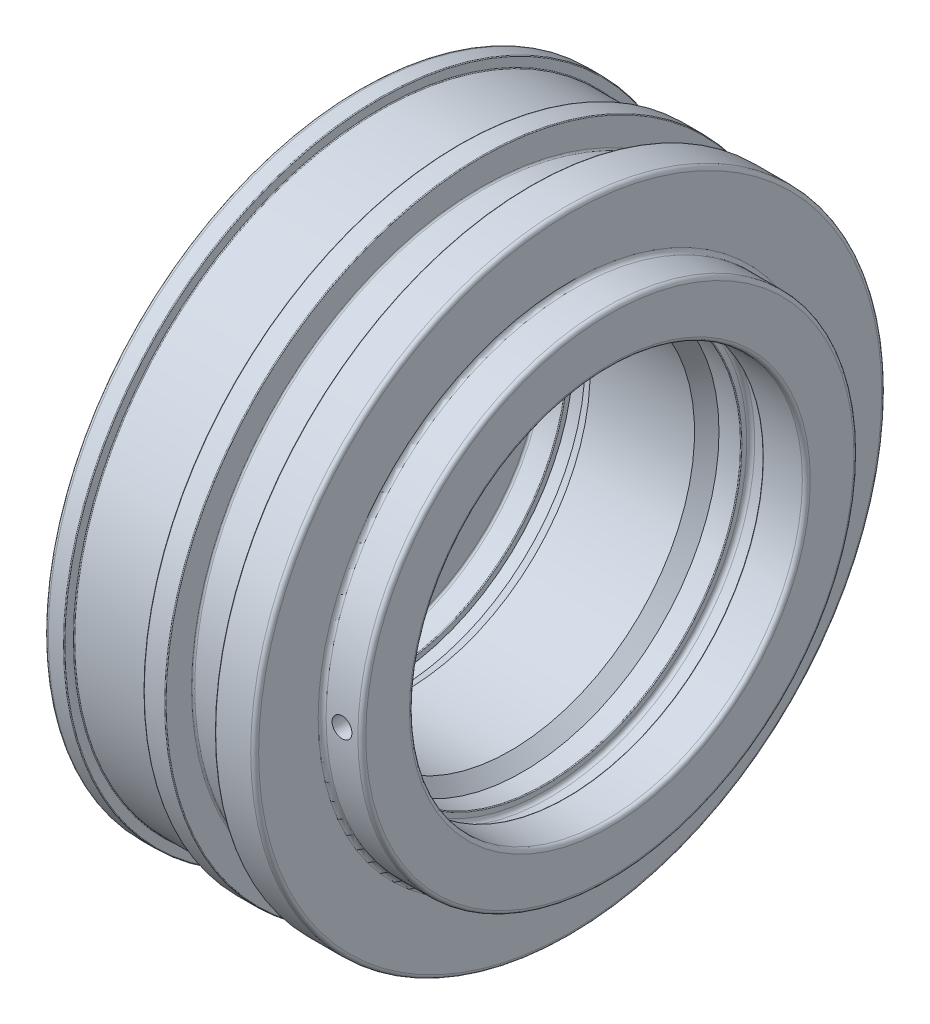
from build123d import *

# Parameters (mm, degrees)
SKETCH2_R          = 2.5
M6_GEVINDHUL_DEPTH = 80.5


with BuildPart() as part:
    # Sketch1 → Base-Revolve (revolve)
    with BuildSketch(Plane.XY):
        with BuildLine():
            Line((15, 67.914213562), (15, 78.5))
            ThreePointArc((15, 78.5), (15.292893219, 79.207106781), (16, 79.5))
            Line((16, 79.5), (19.8, 79.5))
            ThreePointArc((19.8, 79.5), (19.941421356, 79.441421356), (20, 79.3))
            Line((20, 79.3), (20, 77.2))
            ThreePointArc((20, 77.2), (20.058578644, 77.058578644), (20.2, 77))
            Line((20.2, 77), (39.8, 77))
            ThreePointArc((39.8, 77), (39.941421356, 77.058578644), (40, 77.2))
            Line((40, 77.2), (40, 79.3))
            ThreePointArc((40, 79.3), (40.058578644, 79.441421356), (40.2, 79.5))
            Line((40.2, 79.5), (45.3, 79.5))
            ThreePointArc((45.3, 79.5), (45.441421356, 79.441421356), (45.5, 79.3))
            Line((45.5, 79.3), (45.5, 72.9))
            ThreePointArc((45.5, 72.9), (45.617157288, 72.617157288), (45.9, 72.5))
            Line((45.9, 72.5), (57.6, 72.5))
            ThreePointArc((57.6, 72.5), (57.882842712, 72.617157288), (58, 72.9))
            Line((58, 72.9), (58, 79.3))
            ThreePointArc((58, 79.3), (58.058578644, 79.441421356), (58.2, 79.5))
            Line((58.2, 79.5), (67, 79.5))
            ThreePointArc((67, 79.5), (67.707106781, 79.207106781), (68, 78.5))
            Line((68, 78.5), (68, 63.5))
            ThreePointArc((68, 63.5), (68.292893219, 62.792893219), (69, 62.5))
            Line((69, 62.5), (77, 62.5))
            ThreePointArc((77, 62.5), (77.707106781, 62.207106781), (78, 61.5))
            Line((78, 61.5), (78, 50.5))
            ThreePointArc((78, 50.5), (77.707106781, 49.792893219), (77, 49.5))
            Line((77, 49.5), (67.2, 49.5))
            ThreePointArc((67.2, 49.5), (67.058578644, 49.558578644), (67, 49.7))
            Line((67, 49.7), (67, 50.9))
            ThreePointArc((67, 50.9), (66.707106781, 51.607106781), (66, 51.9))
            Line((66, 51.9), (62.6, 51.9))
            ThreePointArc((62.6, 51.9), (61.892893219, 51.607106781), (61.6, 50.9))
            Line((61.6, 50.9), (61.6, 49.7))
            ThreePointArc((61.6, 49.7), (61.541421356, 49.558578644), (61.4, 49.5))
            Line((61.4, 49.5), (56, 49.5))
            Line((56, 49.5), (52.9175, 46.4175))
            Line((52.9175, 46.4175), (26.615178499, 46.4175))
            Line((26.615178499, 46.4175), (24, 47.75))
            Line((24, 47.75), (21, 47.75))
            Line((21, 47.75), (21, 46.45))
            ThreePointArc((21, 46.45), (20.941421356, 46.308578644), (20.8, 46.25))
            Line((20.8, 46.25), (15.5, 46.25))
            ThreePointArc((15.5, 46.25), (15.146446609, 46.103553391), (15, 45.75))
            Line((15, 45.75), (15, 32.5))
            Line((15, 32.5), (20, 18.762612903))
            Line((20, 18.762612903), (20, 0))
            Line((20, 0), (0, 0))
            Line((0, 0), (0, 52.085786438))
            ThreePointArc((0, 52.085786438), (0.076120467, 52.46846987), (0.292893219, 52.792893219))
            Line((0.292893219, 52.792893219), (14.707106781, 67.207106781))
            ThreePointArc((14.707106781, 67.207106781), (14.923879533, 67.53153013), (15, 67.914213562))
        make_face()
    revolve(axis=Axis((-64.519784768, 0, 0), (1, 0, 0)))

    # Sketch2 → M6 gevindhul (cut, through all)
    with BuildSketch(Plane.XY):
        with Locations((73, 0)):
            Circle(SKETCH2_R)
    extrude(amount=M6_GEVINDHUL_DEPTH, mode=Mode.SUBTRACT)


solid = part.part
